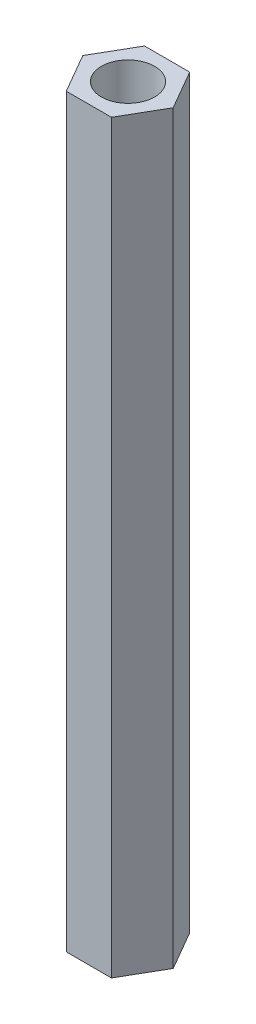
from build123d import *

# Parameters (mm, degrees)
SKETCH_1_R      = 1
EXTRUDE_1_DEPTH = 28


with BuildPart() as part:
    # 草图1 → 凸台-拉伸1 (new body)
    with BuildSketch(Plane(origin=(0, 0, 0), x_dir=(1, 0, 0), z_dir=(0, 1, 0))):
        Polygon((0.848704896, 1.47), (-0.848704896, 1.47), (-1.697409791, 0), (-0.848704896, -1.47), (0.848704896, -1.47), (1.697409791, 0), align=None)
        Circle(SKETCH_1_R, mode=Mode.SUBTRACT)
    extrude(amount=EXTRUDE_1_DEPTH)


solid = part.part
